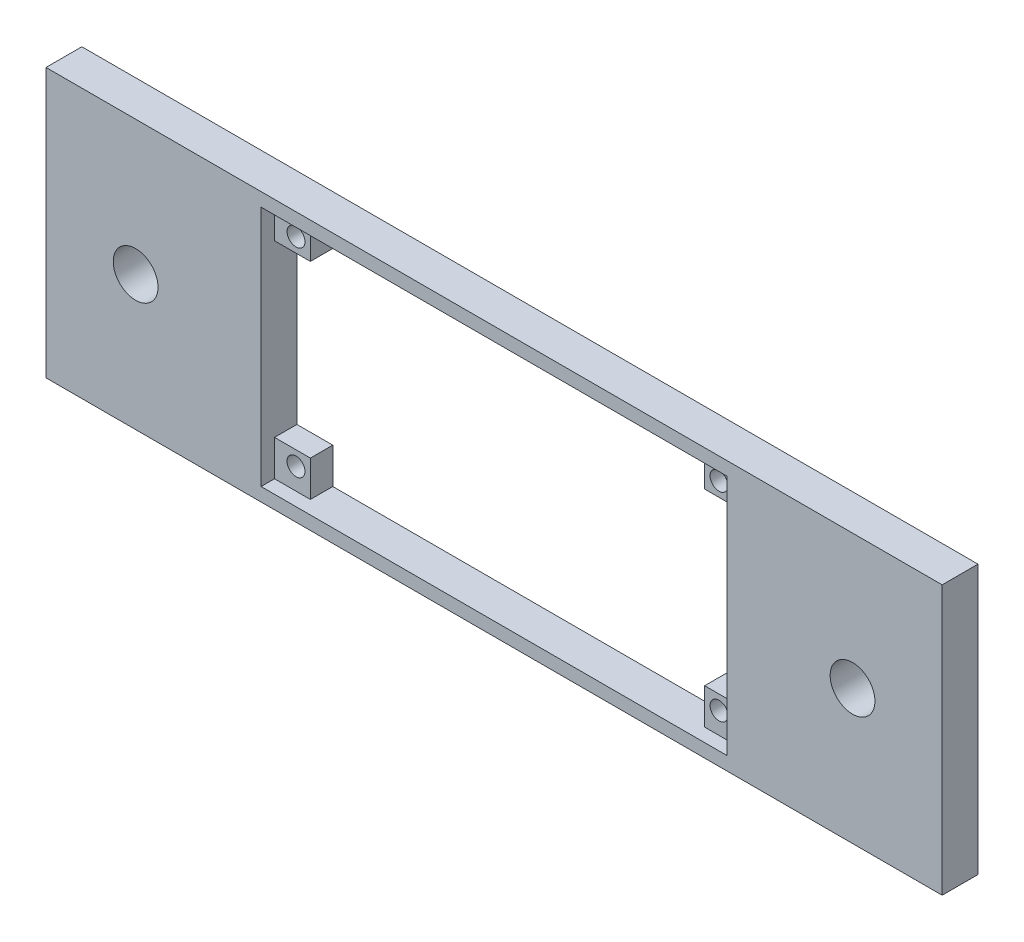
from build123d import *

# Parameters (mm, degrees)
SKETCH1_W           = 100
SKETCH1_H           = 30
SKETCH1_R           = 2.5
SKETCH1_W_2         = 52
SKETCH1_H_2         = 27
BOSS_EXTRUDE1_DEPTH = 4
SKETCH2_W           = 4
SKETCH2_H           = 4
SKETCH2_R           = 1
BOSS_EXTRUDE2_DEPTH = 2.5


with BuildPart() as part:
    # Sketch1 → Boss-Extrude1 (new body)
    with BuildSketch(Plane.XY):
        Rectangle(SKETCH1_W, SKETCH1_H)
        with Locations((-40, 0)):
            Circle(SKETCH1_R, mode=Mode.SUBTRACT)
        with Locations((40, 0)):
            Circle(SKETCH1_R, mode=Mode.SUBTRACT)
        Rectangle(SKETCH1_W_2, SKETCH1_H_2, mode=Mode.SUBTRACT)
    extrude(amount=BOSS_EXTRUDE1_DEPTH)

    # Sketch2 → Boss-Extrude2 (add)
    with BuildSketch(Plane.XY):
        with Locations((24, -11.5)):
            Rectangle(SKETCH2_W, SKETCH2_H)
        with Locations((23.6, -11.1)):
            Circle(SKETCH2_R, mode=Mode.SUBTRACT)
        with Locations((24, 11.5)):
            Rectangle(SKETCH2_W, SKETCH2_H)
        with Locations((23.6, 11.1)):
            Circle(SKETCH2_R, mode=Mode.SUBTRACT)
        with Locations((-24, -11.5)):
            Rectangle(SKETCH2_W, SKETCH2_H)
        with Locations((-23.6, -11.1)):
            Circle(SKETCH2_R, mode=Mode.SUBTRACT)
        with Locations((-24, 11.5)):
            Rectangle(SKETCH2_W, SKETCH2_H)
        with Locations((-23.6, 11.1)):
            Circle(SKETCH2_R, mode=Mode.SUBTRACT)
    extrude(amount=BOSS_EXTRUDE2_DEPTH)


solid = part.part
